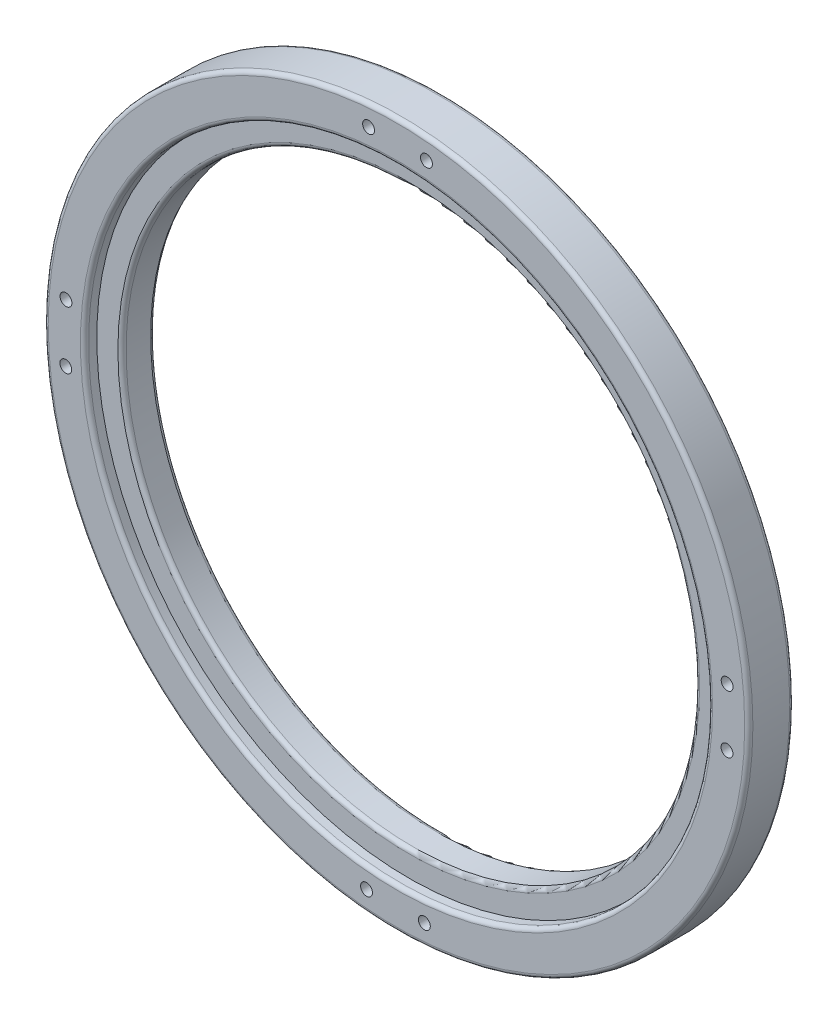
from build123d import *

# Parameters (mm, degrees)
SKETCH_1_R                     = 86
SKETCH_1_R_2                   = 70
EXTRUDE_1_DEPTH                = 8
SKETCH_2_R                     = 86
SKETCH_2_R_2                   = 76.15
EXTRUDE_2_DEPTH                = 3
FILLET_1_R                     = 1
HOLE_WIZARD_M2_5_1_D           = 2.9
HOLE_WIZARD_M2_5_1_CSINK_D     = 2.95
HOLE_WIZARD_M2_5_1_CSINK_ANGLE = 90


with BuildPart() as part:
    # 草图1 → 凸台-拉伸1 (new body)
    with BuildSketch(Plane.XY):
        Circle(SKETCH_1_R)
        Circle(SKETCH_1_R_2, mode=Mode.SUBTRACT)
    extrude(amount=EXTRUDE_1_DEPTH)

    # 草图2 → 凸台-拉伸2 (add)
    with BuildSketch(Plane.XY.offset(8)):
        Circle(SKETCH_2_R)
        Circle(SKETCH_2_R_2, mode=Mode.SUBTRACT)
    extrude(amount=EXTRUDE_2_DEPTH)

    # 圆角1
    fillet_1_edges = [part.edges().sort_by_distance(p)[0] for p in [
        (-86, 0, 11),
        (-76.15, 0, 11),
        (-86, 0, 0),
        (-70, 0, 0),
        (-70, 0, 8),
    ]]
    fillet(fillet_1_edges, radius=FILLET_1_R)

    # M2.5 间隙孔1 (through all)
    with Locations(Plane(origin=(0, 0, 0), x_dir=(-1, 0, 0), z_dir=(0, 0, -1))):
        with Locations((6.808114054, 80.713379207), (-7.311047709, 80.669378214), (80.713379207, -6.808114054), (80.669378214, 7.311047709), (-6.808114054, -80.713379207), (7.311047709, -80.669378214), (-80.713379207, 6.808114054), (-80.669378214, -7.311047709)):
            CounterSinkHole(HOLE_WIZARD_M2_5_1_D / 2, HOLE_WIZARD_M2_5_1_CSINK_D / 2, counter_sink_angle=HOLE_WIZARD_M2_5_1_CSINK_ANGLE)


solid = part.part
